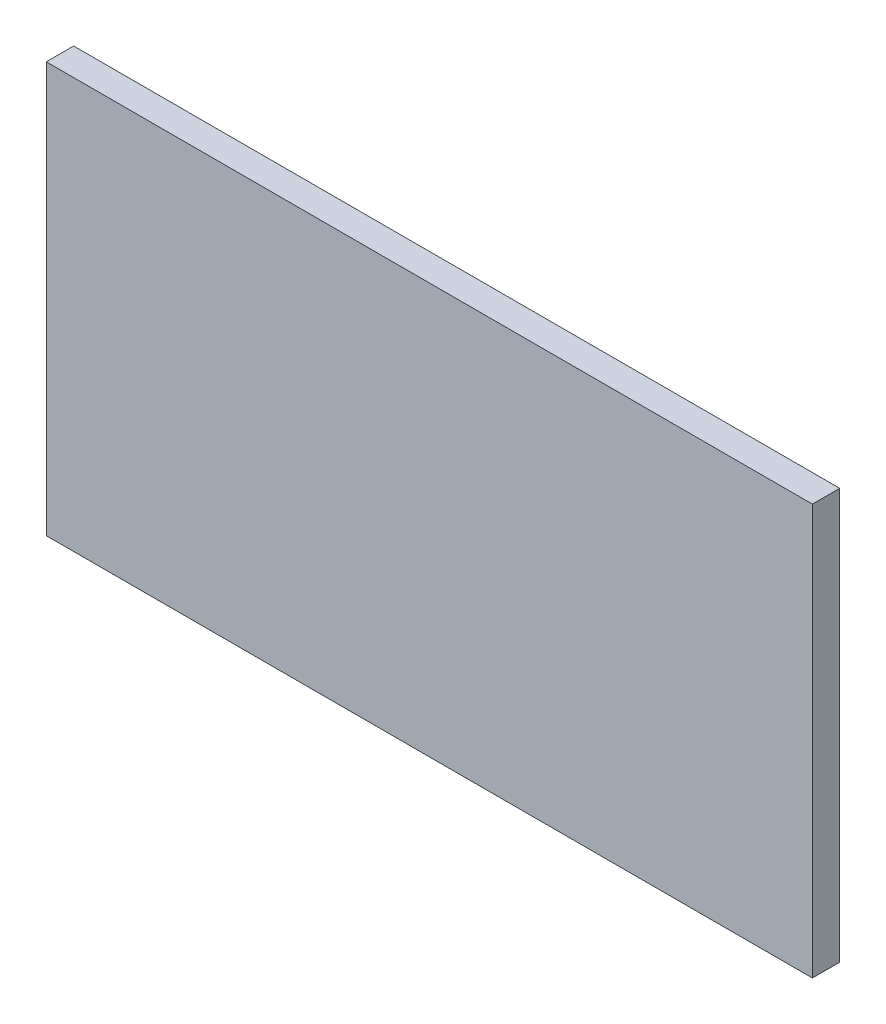
from build123d import *

# Parameters (mm, degrees)
SKETCH1_W           = 177.8
SKETCH1_H           = 95.25
BOSS_EXTRUDE1_DEPTH = 6.35


with BuildPart() as part:
    # Sketch1 → Boss-Extrude1 (new body)
    with BuildSketch(Plane.XY):
        Rectangle(SKETCH1_W, SKETCH1_H)
    extrude(amount=BOSS_EXTRUDE1_DEPTH)


solid = part.part
